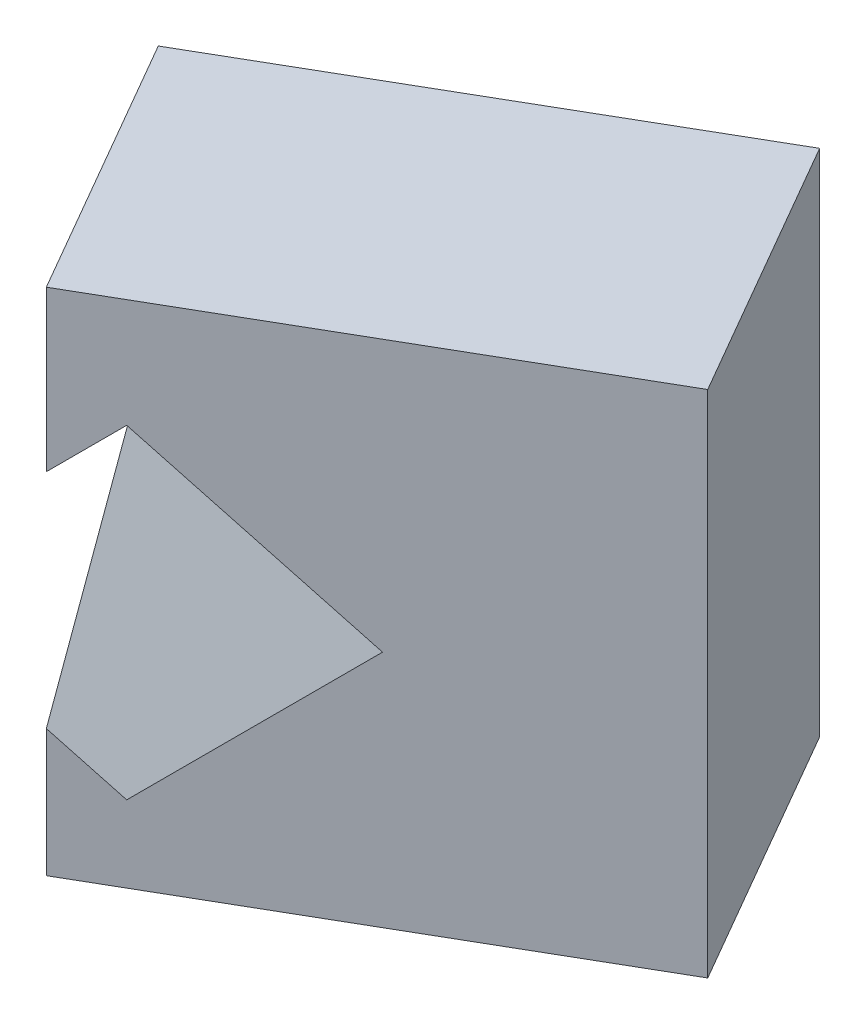
from build123d import *

# Parameters (mm, degrees)
EXTRUDE1_DEPTH     = 100
CUT_EXTRUDE1_DEPTH = 100.461524227


with BuildPart() as part:
    # Sketch1 → Extrude1 (new body)
    with BuildSketch(Plane(origin=(0, 0, 0), x_dir=(1, 0, 0), z_dir=(0, 1, 0))):
        Polygon((0, 0), (30, -51.961524227), (-52.27241336, -99.461524227), (-82.27241336, -47.5), align=None)
    extrude(amount=EXTRUDE1_DEPTH)

    # Sketch2 → Cut-Extrude1 (cut, through all)
    with BuildSketch(Plane.XY):
        Polygon((-42.27241336, 78.639610307), (-10.452608206, 46.819805153), (-42.27241336, 15), (-74.092218513, 46.819805153), align=None)
    extrude(amount=CUT_EXTRUDE1_DEPTH, mode=Mode.SUBTRACT)


solid = part.part
